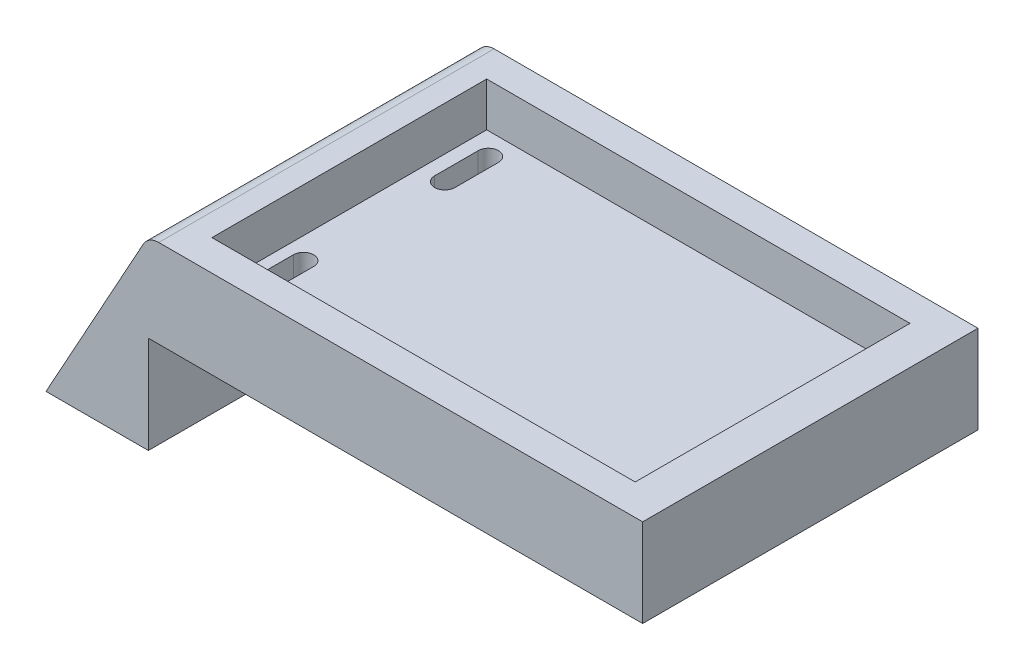
from build123d import *

# Parameters (mm, degrees)
SKETCH1_W           = 71.272685497
SKETCH1_H           = 48.354613482
BOSS_EXTRUDE1_DEPTH = 12.7
SKETCH2_W           = 61.031917372
SKETCH2_H           = 39.617209522
CUT_EXTRUDE1_DEPTH  = 6.35
BOSS_EXTRUDE2_DEPTH = 48.354613
FILLET1_R           = 2.54
SKETCH5_R           = 7.62
CUT_EXTRUDE2_DEPTH  = 2.54
CUT_EXTRUDE3_DEPTH  = 6.35
CUT_REVOLVE1_ANGLE  = 180


with BuildPart() as part:
    # Sketch1 → Boss-Extrude1 (new body)
    with BuildSketch(Plane(origin=(0, 0, 0), x_dir=(1, 0, 0), z_dir=(0, 1, 0))):
        with Locations((0.881464309, -2.644392925)):
            Rectangle(SKETCH1_W, SKETCH1_H)
    extrude(amount=-BOSS_EXTRUDE1_DEPTH)

    # Sketch2 → Cut-Extrude1 (cut)
    with BuildSketch(Plane(origin=(0, 0, 0), x_dir=(1, 0, 0), z_dir=(0, 1, 0))):
        with Locations((0.488861331, -2.573010565)):
            Rectangle(SKETCH2_W, SKETCH2_H)
    extrude(amount=-CUT_EXTRUDE1_DEPTH, mode=Mode.SUBTRACT)

    # Sketch4 → Boss-Extrude2 (add)
    with BuildSketch(Plane.XY.offset(26.821699666)):
        Polygon((-34.75487844, -12.7), (-34.75487844, -26.729663637), (-49.514481499, -26.729663637), (-34.75487844, 0), align=None)
    extrude(amount=-BOSS_EXTRUDE2_DEPTH)

    # Fillet1
    fillet1_edges = [part.edges().sort_by_distance(p)[0] for p in [
        (-34.75487844, 0, 2.644392925),
    ]]
    fillet(fillet1_edges, radius=FILLET1_R)

    # Sketch5 → Cut-Extrude2 (cut)
    with BuildSketch(Plane(origin=(0, 0, -21.532913816), x_dir=(-1, 0, 0), z_dir=(0, 0, -1))):
        with Locations((-13.922709082, -12.7)):
            Circle(SKETCH5_R)
    extrude(amount=-CUT_EXTRUDE2_DEPTH, mode=Mode.SUBTRACT)

    # Sketch7 → Cut-Extrude3 (cut)
    with BuildSketch(Plane(origin=(0, -6.35, 0), x_dir=(1, 0, 0), z_dir=(0, 1, 0))):
        with BuildLine():
            Line((-25.109899832, 14.028476446), (-25.109899832, 7.738453376))
            ThreePointArc((-25.109899832, 7.738453376), (-26.574699725, 6.273653483), (-28.039499618, 7.738453376))
            Line((-28.039499618, 7.738453376), (-28.039499618, 14.028476446))
            ThreePointArc((-28.039499618, 14.028476446), (-26.574699725, 15.493276339), (-25.109899832, 14.028476446))
        make_face()
        with BuildLine():
            Line((-25.435843167, -12.298214097), (-25.435843167, -18.588237167))
            ThreePointArc((-25.435843167, -18.588237167), (-26.90064306, -20.05303706), (-28.365442953, -18.588237167))
            Line((-28.365442953, -18.588237167), (-28.365442953, -12.298214097))
            ThreePointArc((-28.365442953, -12.298214097), (-26.90064306, -10.833414204), (-25.435843167, -12.298214097))
        make_face()
    extrude(amount=-CUT_EXTRUDE3_DEPTH, mode=Mode.SUBTRACT)

    # Sketch9 → Cut-Revolve1 (revolve, cut)
    with BuildSketch(Plane(origin=(-34.75487844, 0, 0), x_dir=(0, 0, -1), z_dir=(1, 0, 0))):
        Polygon((-2.644392925, -26.729663637), (-2.644392925, -13.548328756), (-0.340047454, -13.548328756), (3.5393378, -26.729663637), align=None)
    revolve(axis=Axis((-34.75487844, -26.729663637, 2.644392925), (0, 1, 0)), revolution_arc=CUT_REVOLVE1_ANGLE, mode=Mode.SUBTRACT)


solid = part.part
